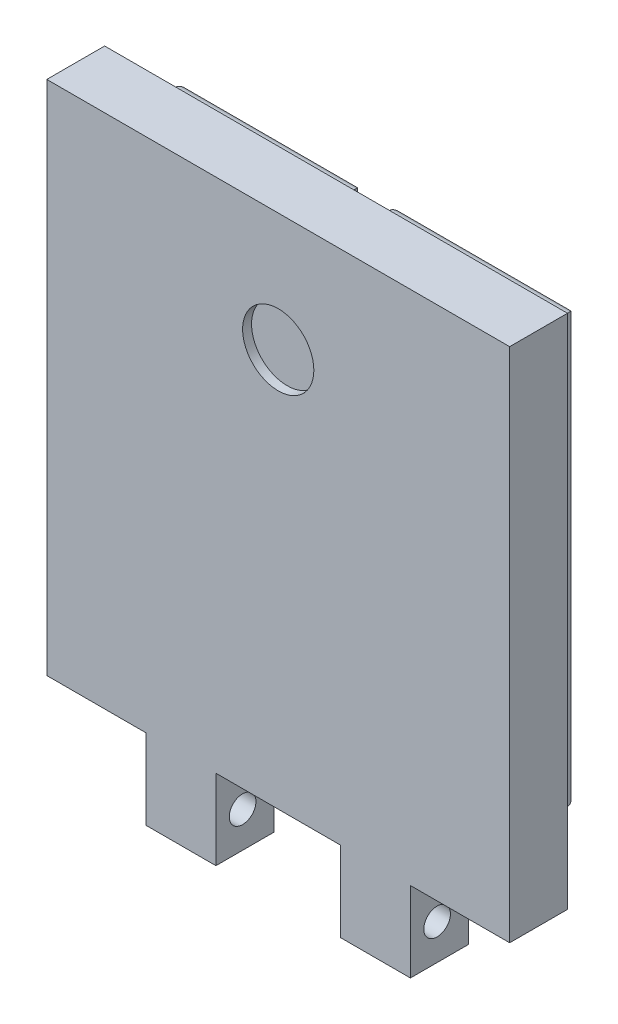
from build123d import *

# Parameters (mm, degrees)
SKETCH1_W            = 29.7
SKETCH1_H            = 67
BOSS_EXTRUDE1_DEPTH  = 6
SKETCH2_R            = 1.5
CUT_EXTRUDE1_DEPTH   = 87
SKETCH3_W            = 42
SKETCH3_H            = 6
BOSS_EXTRUDE2_DEPTH  = 58
SKETCH4_W            = 14
SKETCH4_H            = 9
CUT_EXTRUDE2_DEPTH   = 58
SKETCH8_W            = 5
SKETCH8_H            = 58
BOSS_EXTRUDE5_DEPTH  = 6
BOSS_EXTRUDE3_DEPTH  = 0.5
BOSS_EXTRUDE4_DEPTH  = 5
FILLET1_R            = 1
FILLET1_OF_MIRROR1_R = 1
SKETCH7_R            = 4
CUT_EXTRUDE3_DEPTH   = 1


with BuildPart() as part:
    # Sketch1 → Boss-Extrude1 (new body)
    with BuildSketch(Plane.XY):
        Rectangle(SKETCH1_W, SKETCH1_H)
    extrude(amount=BOSS_EXTRUDE1_DEPTH)

    # Sketch2 → Cut-Extrude1 (cut)
    with BuildSketch(Plane(origin=(14.85, 0, 0), x_dir=(0, 0, -1), z_dir=(1, 0, 0))):
        with Locations((-3, -29.5)):
            Circle(SKETCH2_R)
    extrude(amount=-CUT_EXTRUDE1_DEPTH, mode=Mode.SUBTRACT)

    # Sketch3 → Boss-Extrude2 (add)
    with BuildSketch(Plane(origin=(0, 33.5, 0), x_dir=(1, 0, 0), z_dir=(0, 1, 0))):
        with Locations((0, -3)):
            Rectangle(SKETCH3_W, SKETCH3_H)
    extrude(amount=-BOSS_EXTRUDE2_DEPTH)

    # Sketch4 → Cut-Extrude2 (cut)
    with BuildSketch(Plane(origin=(0, 0, 0), x_dir=(-1, 0, 0), z_dir=(0, 0, -1))):
        with Locations((0, -29)):
            Rectangle(SKETCH4_W, SKETCH4_H)
    extrude(amount=-CUT_EXTRUDE2_DEPTH, mode=Mode.SUBTRACT)

    # Sketch8 → Boss-Extrude5 (add)
    with BuildSketch(Plane.XY.offset(6)):
        with Locations((-23.5, 4.5)):
            Rectangle(SKETCH8_W, SKETCH8_H)
        with Locations((23.5, 4.5)):
            Rectangle(SKETCH8_W, SKETCH8_H)
    extrude(amount=-BOSS_EXTRUDE5_DEPTH)

    # Sketch5 → Boss-Extrude3 (add)
    with BuildSketch(Plane(origin=(0, 0, 0), x_dir=(-1, 0, 0), z_dir=(0, 0, -1))):
        Polygon((26, -24.5), (26, 33.5), (-26, 33.5), (-26, -24.5), (-14.85, -24.5), (-14.85, -33.5), (-7, -33.5), (-7, -24.5), (7, -24.5), (7, -33.5), (14.85, -33.5), (14.85, -24.5), align=None)
    extrude(amount=BOSS_EXTRUDE3_DEPTH)

    # Sketch6 → Boss-Extrude4 (add)
    with BuildSketch(Plane(origin=(0, 0, -0.5), x_dir=(-1, 0, 0), z_dir=(0, 0, -1))):
        Polygon((-22, 29.5), (-22, -18.5), (-18, -18.5), (-18, 25.5), (-2, 25.5), (-2, 29.5), align=None)
    boss_extrude4 = extrude(amount=BOSS_EXTRUDE4_DEPTH)

    # Fillet1
    fillet1_edges = [part.edges().sort_by_distance(p)[0] for p in [
        (12, 29.5, -5.5),
        (22, 5.5, -5.5),
        (20, -18.5, -5.5),
        (18, 3.5, -5.5),
        (10, 25.5, -5.5),
        (2, 27.5, -5.5),
    ]]
    fillet(fillet1_edges, radius=FILLET1_R)

    # Mirror1: Boss-Extrude4 across plane
    add(boss_extrude4.mirror(Plane(origin=(0, 0, 0), x_dir=(0, 0, 1), z_dir=(1, 0, 0))))

    # Fillet1 of Mirror1
    fillet1_of_mirror1_edges = [part.edges().sort_by_distance(p)[0] for p in [
        (-12, 29.5, -5.5),
        (-22, 5.5, -5.5),
        (-20, -18.5, -5.5),
        (-18, 3.5, -5.5),
        (-10, 25.5, -5.5),
        (-2, 27.5, -5.5),
    ]]
    fillet(fillet1_of_mirror1_edges, radius=FILLET1_OF_MIRROR1_R)

    # Sketch7 → Cut-Extrude3 (cut)
    with BuildSketch(Plane.XY.offset(6)):
        with Locations((0, 20.200252003)):
            Circle(SKETCH7_R)
    extrude(amount=-CUT_EXTRUDE3_DEPTH, mode=Mode.SUBTRACT)


solid = part.part
